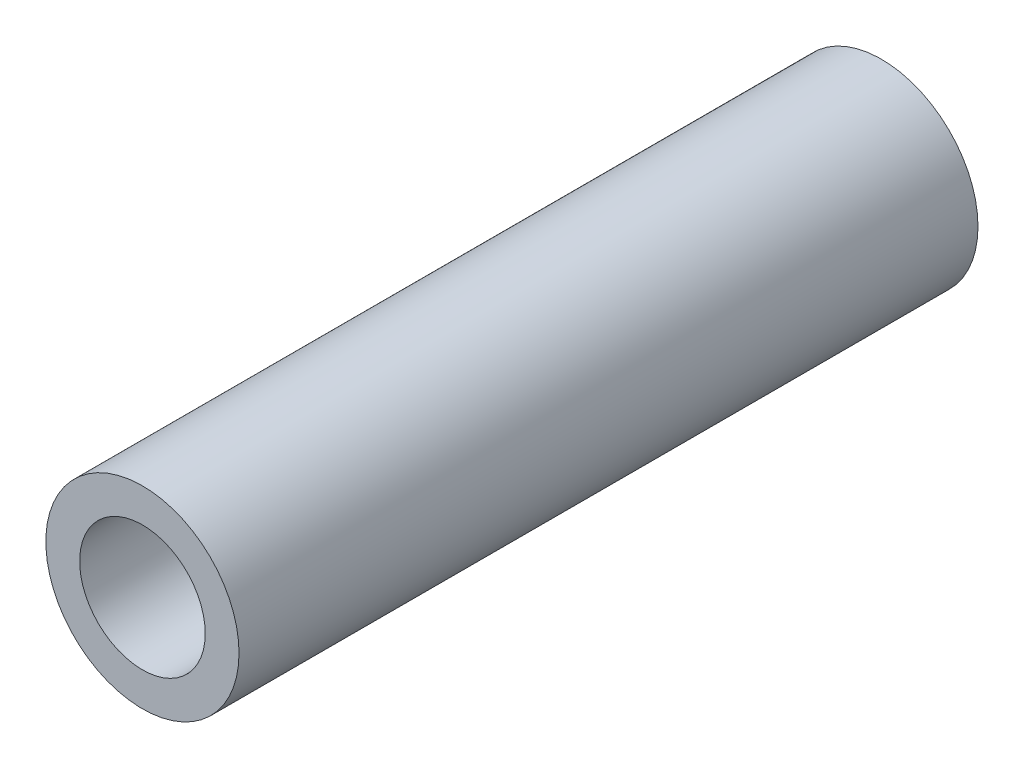
from build123d import *

# Parameters (mm, degrees)
SKETCH1_R           = 2
BOSS_EXTRUDE1_DEPTH = 15.3
SKETCH2_R           = 1.3
CUT_EXTRUDE1_DEPTH  = 16.3


with BuildPart() as part:
    # Sketch1 → Boss-Extrude1 (new body)
    with BuildSketch(Plane.XY):
        Circle(SKETCH1_R)
    extrude(amount=-BOSS_EXTRUDE1_DEPTH)

    # Sketch2 → Cut-Extrude1 (cut, through all)
    with BuildSketch(Plane.XY):
        Circle(SKETCH2_R)
    extrude(amount=-CUT_EXTRUDE1_DEPTH, mode=Mode.SUBTRACT)


solid = part.part
